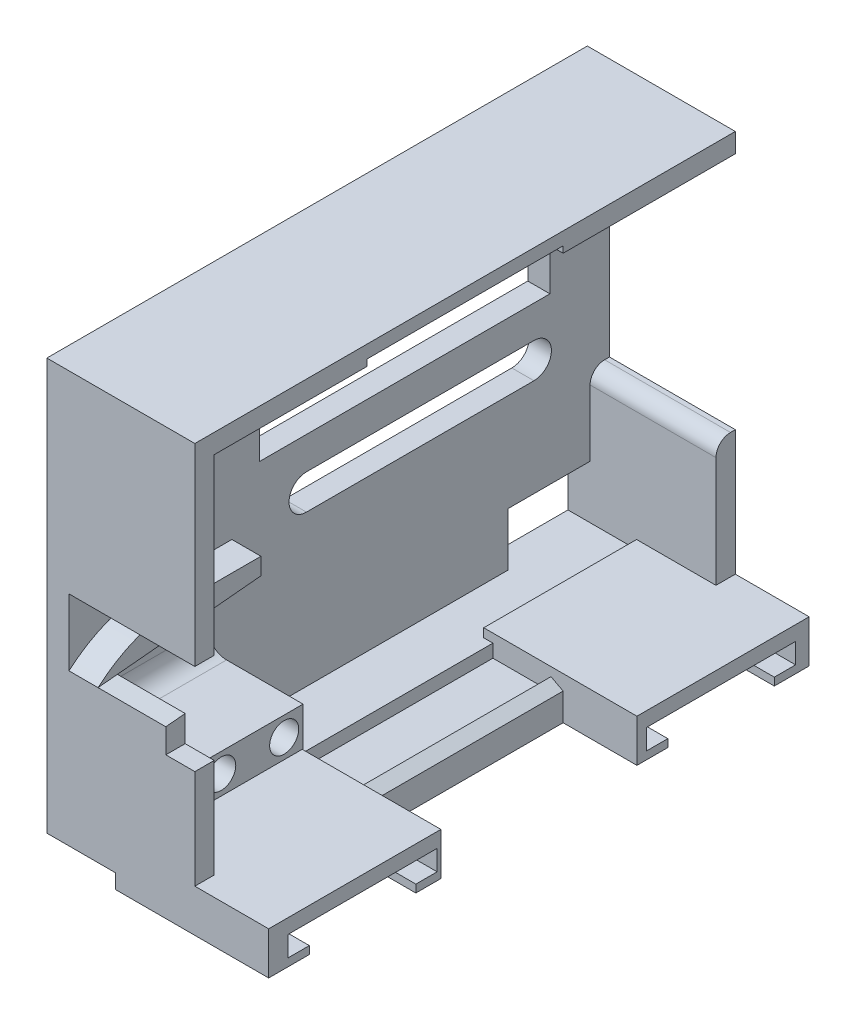
from build123d import *

# Parameters (mm, degrees)
MAIN_EXTRUDE_DEPTH            = 2.2875
WALLS_START                   = 2.2875
WALLS_DEPTH                   = 13
CORNER_SUPPORT_DEPTH          = 2
SKETCH2_R                     = 0.95
SKETCH2_W                     = 2.4
SKETCH2_H                     = 4
SKETCH2_W_2                   = 1
SWITCH_SPACER_DEPTH           = 9.9
ARM_SUPPORT_EXTRUDE_DEPTH     = 3
ARM_SUPPORT_CURVE_DEPTH       = 40.380356778
FILLET4_R                     = 2
FILLET3_R                     = 2
SKETCH2_5_R                   = 0.95
SWITCH_MOUNT_HOLES_DEPTH      = 40.380356889
SWITCH_MOUNT_HOLES_DEPTH_BACK = 40.380356889
SKETCH35_R                    = 1.5
SWITCH_MOUNT_EXIT_HOLES_DEPTH = 3
SKETCH4_W                     = 8.5
SKETCH4_H                     = 5.5
WIRE_HOLE_DEPTH               = 40.380356889
SKETCH25_W                    = 6
SKETCH25_H                    = 1.35
FEMALE_SNAP_DEPTH             = 10.125
SKETCH5_W                     = 30
SKETCH5_H                     = 12.75
SERVO_HOLE_DEPTH              = 40.380356889
SKETCH30_W                    = 15.7875
SKETCH30_H                    = 0.9
SKETCH30_W_2                  = 17.7875
SKETCH30_H_2                  = 1.5
MAGNET_EXTRUDE_1_DEPTH        = 7.625
MAGNET_EXTRUDE_1_DEPTH_BACK   = 8.2
SKETCH30_5_W                  = 20.25
SKETCH30_5_H                  = 1.5
MAGNET_EXTRUDE_2_DEPTH        = 8.2
SKETCH29_R                    = 7.7
MAGNET_HOLE_DEPTH             = 2.1
SKETCH31_R                    = 5.5
MAGNET_THRU_HOLE_DEPTH        = 58.632218961
SKETCH39_W                    = 3.175
SKETCH39_H                    = 12.55
CUT_EXTRUDE1_DEPTH            = 45.416158798
CUT_EXTRUDE2_DEPTH            = 42.895144408
BOSS_EXTRUDE2_DEPTH           = 10


with BuildPart() as part:
    # Sketch1 → Main Extrude (new body)
    with BuildSketch(Plane(origin=(0, 0, 0), x_dir=(0, 0, -1), z_dir=(1, 0, 0))):
        Polygon((-30.5, -9.35), (-27.325, -9.35), (-27.325, -21.25), (28.5, -21.25), (28.5, 21.25), (-27.325, 21.25), (-27.325, 3.2), (-30.5, 3.2), align=None)
        with BuildLine():
            Line((20.7, -3.65), (-2.8, -3.65))
            ThreePointArc((-2.8, -3.65), (-4.6, -1.85), (-2.8, -0.05))
            Line((-2.8, -0.05), (20.7, -0.05))
            ThreePointArc((20.7, -0.05), (22.5, -1.85), (20.7, -3.65))
        make_face(mode=Mode.SUBTRACT)
    extrude(amount=MAIN_EXTRUDE_DEPTH)

    # Sketch1_3 → Walls (add)
    with BuildSketch(Plane(origin=(0, 0, 0), x_dir=(0, 0, -1), z_dir=(1, 0, 0)).offset(WALLS_START)):
        Polygon((-25.325, 19.25), (28.5, 19.25), (28.5, 21.25), (-27.325, 21.25), (-27.325, 3.2), (-30.5, 3.2), (-30.5, 1.3), (-25.325, 1.3), align=None)
        with BuildLine():
            Line((28.5, -5.425), (28, -5.425))
            ThreePointArc((28, -5.425), (26.939339828, -5.864339828), (26.5, -6.925))
            Line((26.5, -6.925), (26.5, -19.25))
            Line((26.5, -19.25), (-25.325, -19.25))
            Line((-25.325, -19.25), (-25.325, -8.1))
            Line((-25.325, -8.1), (-28.5, -8.1))
            Line((-28.5, -8.1), (-28.5, -4.45))
            Line((-28.5, -4.45), (-30.5, -4.45))
            Line((-30.5, -4.45), (-30.5, -9.35))
            Line((-30.5, -9.35), (-27.325, -9.35))
            Line((-27.325, -9.35), (-27.325, -21.25))
            Line((-27.325, -21.25), (28.5, -21.25))
            Line((28.5, -21.25), (28.5, -5.425))
        make_face()
    extrude(amount=WALLS_DEPTH)

    # Sketch22 → Corner Support (add)
    with BuildSketch(Plane(origin=(0, 0, -28.5), x_dir=(-1, 0, 0), z_dir=(0, 0, -1))):
        Polygon((-4.2875, 19.25), (-2.2875, 18.25), (-2.2875, 19.25), align=None)
    extrude(amount=-CORNER_SUPPORT_DEPTH)

    # Sketch2 → Switch Spacer (add)
    with BuildSketch(Plane(origin=(2.2875, 0, 0), x_dir=(0, 0, -1), z_dir=(1, 0, 0))):
        Polygon((-14.05, -10.75), (-17.05, -10.75), (-17.05, -14.75), (-14.05, -14.75), (-14.05, -12.75), align=None)
        with Locations((-15, -12.75)):
            Circle(SKETCH2_R, mode=Mode.SUBTRACT)
        with Locations((-15, -12.75)):
            Circle(SKETCH2_R)
        Polygon((-19.45, -10.75), (-22.45, -10.75), (-22.45, -12.75), (-22.45, -14.75), (-19.45, -14.75), align=None)
        with BuildLine():
            ThreePointArc((-20.55, -12.75), (-21.5, -13.7), (-22.45, -12.75))
            ThreePointArc((-22.45, -12.75), (-21.5, -11.8), (-20.55, -12.75))
        make_face(mode=Mode.SUBTRACT)
        with Locations((-21.5, -12.75)):
            Circle(SKETCH2_R)
        Polygon((-22.45, -12.75), (-22.45, -10.75), (-25.325, -10.75), (-25.325, -14.75), (-22.45, -14.75), align=None)
        with Locations((-18.25, -12.75)):
            Rectangle(SKETCH2_W, SKETCH2_H)
        with Locations((-13.55, -12.75)):
            Rectangle(SKETCH2_W_2, SKETCH2_H)
    extrude(amount=SWITCH_SPACER_DEPTH)

    # Sketch3 → Arm Support Extrude (add)
    with BuildSketch(Plane(origin=(2.2875, 0, 0), x_dir=(0, 0, -1), z_dir=(1, 0, 0))):
        with BuildLine():
            Line((-18.5, -2.25), (-10.5, -2.25))
            Line((-10.5, -2.25), (-10.5, -4))
            Line((-10.5, -4), (-28.5, -5.7))
            Line((-28.5, -5.7), (-30.5, -5.7))
            ThreePointArc((-30.5, -5.7), (-24.743046131, -3.129622151), (-18.5, -2.25))
        make_face()
    extrude(amount=ARM_SUPPORT_EXTRUDE_DEPTH)

    # Sketch7 → Arm Support Curve (cut, through all)
    with BuildSketch(Plane(origin=(2.2875, 0, 0), x_dir=(0, 0, -1), z_dir=(1, 0, 0))):
        with BuildLine():
            Line((-28.5, -4.583410824), (-28.5, -4.45))
            Line((-28.5, -4.45), (-30.5, -4.45))
            Line((-30.5, -4.45), (-30.5, -5.7))
            ThreePointArc((-30.5, -5.7), (-29.627655409, -5.180138898), (-28.73283292, -4.7))
            ThreePointArc((-28.73283292, -4.7), (-28.616584416, -4.641369997), (-28.5, -4.583410824))
        make_face()
    extrude(amount=ARM_SUPPORT_CURVE_DEPTH, mode=Mode.SUBTRACT)

    # Fillet4
    fillet4_edges = [part.edges().sort_by_distance(p)[0] for p in [
        (2.2875, -2.2, 30.5),
    ]]
    fillet(fillet4_edges, radius=FILLET4_R)

    # Fillet3
    fillet3_edges = [part.edges().sort_by_distance(p)[0] for p in [
        (2.2875, -14.75, 19.1875),
        (2.2875, -10.75, 19.1875),
    ]]
    fillet(fillet3_edges, radius=FILLET3_R)

    # Sketch2_5 → Switch Mount Holes (cut, two sides)
    with BuildSketch(Plane(origin=(2.2875, 0, 0), x_dir=(0, 0, -1), z_dir=(1, 0, 0))) as switch_mount_holes_sk:
        with Locations((-21.5, -12.75)):
            Circle(SKETCH2_5_R)
        with Locations((-15, -12.75)):
            Circle(SKETCH2_5_R)
    extrude(amount=SWITCH_MOUNT_HOLES_DEPTH, mode=Mode.SUBTRACT)
    extrude(switch_mount_holes_sk.sketch, amount=-SWITCH_MOUNT_HOLES_DEPTH_BACK, mode=Mode.SUBTRACT)

    # Sketch35 → Switch Mount Exit Holes (cut)
    with BuildSketch(Plane(origin=(12.1875, 0, 0), x_dir=(0, 0, -1), z_dir=(1, 0, 0))):
        with Locations((-21.5, -12.75)):
            Circle(SKETCH35_R)
        with Locations((-15, -12.75)):
            Circle(SKETCH35_R)
    extrude(amount=-SWITCH_MOUNT_EXIT_HOLES_DEPTH, mode=Mode.SUBTRACT)

    # Sketch4 → Wire Hole (cut, through all)
    with BuildSketch(Plane(origin=(2.2875, 0, 0), x_dir=(0, 0, -1), z_dir=(1, 0, 0))):
        with Locations((22.25, -16.5)):
            Rectangle(SKETCH4_W, SKETCH4_H)
    extrude(amount=-WIRE_HOLE_DEPTH, mode=Mode.SUBTRACT)

    # Sketch25 → Female Snap (cut, symmetric)
    with BuildSketch(Plane(origin=(0, 0, -0.5875), x_dir=(-1, 0, 0), z_dir=(0, 0, -1))):
        with Locations((-11.0375, -19.925)):
            Rectangle(SKETCH25_W, SKETCH25_H)
        Polygon((-15.2875, -19.25), (-15.2875, -19.91463679), (-14.0375, -19.25), align=None)
        with Locations((-11.0375, 19.925)):
            Rectangle(SKETCH25_W, SKETCH25_H)
        Polygon((-15.2875, 19.91463679), (-15.2875, 19.25), (-14.0375, 19.25), align=None)
    extrude(amount=FEMALE_SNAP_DEPTH, both=True, mode=Mode.SUBTRACT)

    # Sketch5 → Servo Hole (cut, through all)
    with BuildSketch(Plane(origin=(2.2875, 0, 0), x_dir=(0, 0, -1), z_dir=(1, 0, 0))):
        with Locations((7.35, 9.675)):
            Rectangle(SKETCH5_W, SKETCH5_H)
        with BuildLine():
            Line((-8.75, 10.675), (-8.75, 8.675))
            ThreePointArc((-8.75, 8.675), (-10.3, 7.125), (-11.85, 8.675))
            Line((-11.85, 8.675), (-11.85, 10.675))
            ThreePointArc((-11.85, 10.675), (-10.3, 12.225), (-8.75, 10.675))
        make_face()
        with BuildLine():
            Line((26.55, 10.675), (26.55, 8.675))
            ThreePointArc((26.55, 8.675), (25, 7.125), (23.45, 8.675))
            Line((23.45, 8.675), (23.45, 10.675))
            ThreePointArc((23.45, 10.675), (25, 12.225), (26.55, 10.675))
        make_face()
    extrude(amount=-SERVO_HOLE_DEPTH, mode=Mode.SUBTRACT)

    # Sketch30 → Magnet Extrude 1 (add, two sides)
    with BuildSketch(Plane(origin=(15.2875, 0, 0), x_dir=(0, 0, -1), z_dir=(1, 0, 0))) as magnet_extrude_1_sk:
        Polygon((-27.325, -18.35), (-27.325, -21.25), (-9.5375, -21.25), (-9.5375, -19.91463679), (-9.5375, -19.25), (-25.325, -19.25), (-25.325, -18.35), align=None)
        with Locations((-17.43125, -18.8)):
            Rectangle(SKETCH30_W, SKETCH30_H)
        with Locations((19.60625, -22)):
            Rectangle(SKETCH30_W_2, SKETCH30_H_2)
        Polygon((10.7125, -19.91463679), (10.7125, -21.25), (28.5, -21.25), (28.5, -18.35), (26.5, -18.35), (26.5, -19.25), (10.7125, -19.25), align=None)
        with Locations((-18.43125, -22)):
            Rectangle(SKETCH30_W_2, SKETCH30_H_2)
        with Locations((18.60625, -18.8)):
            Rectangle(SKETCH30_W, SKETCH30_H)
    extrude(amount=MAGNET_EXTRUDE_1_DEPTH)
    extrude(magnet_extrude_1_sk.sketch, amount=-MAGNET_EXTRUDE_1_DEPTH_BACK)

    # Sketch30_5 → Magnet Extrude 2 (add)
    with BuildSketch(Plane(origin=(15.2875, 0, 0), x_dir=(0, 0, -1), z_dir=(1, 0, 0))):
        with Locations((0.5875, -22)):
            Rectangle(SKETCH30_5_W, SKETCH30_5_H)
    extrude(amount=-MAGNET_EXTRUDE_2_DEPTH)

    # Sketch29 → Magnet Hole (cut)
    with BuildSketch(Plane(origin=(0, -21.95, 0), x_dir=(1, 0, 0), z_dir=(0, 1, 0))):
        with Locations((15.2875, -17.625)):
            Circle(SKETCH29_R)
        with BuildLine():
            ThreePointArc((22.9125, -18.697089082), (20.338980677, -23.436414885), (15.2875, -25.325))
            Line((15.2875, -25.325), (22.9125, -25.325))
            Line((22.9125, -25.325), (22.9125, -18.697089082))
        make_face()
        with BuildLine():
            Line((22.9125, -9.925), (15.2875, -9.925))
            ThreePointArc((15.2875, -9.925), (20.338980677, -11.813585115), (22.9125, -16.552910918))
            Line((22.9125, -16.552910918), (22.9125, -9.925))
        make_face()
        with Locations((15.2875, 19.4)):
            Circle(SKETCH29_R)
        with BuildLine():
            ThreePointArc((22.9125, 18.327910918), (20.338980677, 13.588585115), (15.2875, 11.7))
            Line((15.2875, 11.7), (22.9125, 11.7))
            Line((22.9125, 11.7), (22.9125, 18.327910918))
        make_face()
        with BuildLine():
            Line((22.9125, 27.1), (15.2875, 27.1))
            ThreePointArc((15.2875, 27.1), (20.338980677, 25.211414885), (22.9125, 20.472089082))
            Line((22.9125, 20.472089082), (22.9125, 27.1))
        make_face()
        with BuildLine():
            ThreePointArc((22.9875, -17.625), (22.968727116, -17.087645368), (22.9125, -16.552910918))
            Line((22.9125, -16.552910918), (22.9125, -18.697089082))
            ThreePointArc((22.9125, -18.697089082), (22.968727116, -18.162354632), (22.9875, -17.625))
        make_face()
        with BuildLine():
            Line((22.9125, 20.472089082), (22.9125, 18.327910918))
            ThreePointArc((22.9125, 18.327910918), (22.968727116, 18.862645368), (22.9875, 19.4))
            ThreePointArc((22.9875, 19.4), (22.968727116, 19.937354632), (22.9125, 20.472089082))
        make_face()
    extrude(amount=MAGNET_HOLE_DEPTH, mode=Mode.SUBTRACT)

    # Sketch31 → Magnet Thru Hole (cut, through all)
    with BuildSketch(Plane.XZ.offset(21.95)):
        with Locations((15.2875, 17.625)):
            Circle(SKETCH31_R)
        with BuildLine():
            Line((22.9125, 23.125), (15.2875, 23.125))
            ThreePointArc((15.2875, 23.125), (19.176587297, 21.514087297), (20.7875, 17.625))
            ThreePointArc((20.7875, 17.625), (19.176587297, 13.735912703), (15.2875, 12.125))
            Line((15.2875, 12.125), (22.9125, 12.125))
            Line((22.9125, 12.125), (22.9125, 23.125))
        make_face()
        with Locations((15.2875, -19.4)):
            Circle(SKETCH31_R)
        with BuildLine():
            Line((22.9125, -13.9), (15.2875, -13.9))
            ThreePointArc((15.2875, -13.9), (19.176587297, -15.510912703), (20.7875, -19.4))
            ThreePointArc((20.7875, -19.4), (19.176587297, -23.289087297), (15.2875, -24.9))
            Line((15.2875, -24.9), (22.9125, -24.9))
            Line((22.9125, -24.9), (22.9125, -13.9))
        make_face()
    extrude(amount=MAGNET_THRU_HOLE_DEPTH, mode=Mode.SUBTRACT)

    # Sketch39 → Cut-Extrude1 (cut, through all)
    with BuildSketch(Plane.ZY):
        with Locations((28.9125, -3.075)):
            Rectangle(SKETCH39_W, SKETCH39_H)
    extrude(amount=-CUT_EXTRUDE1_DEPTH, mode=Mode.SUBTRACT)

    # Sketch40 → Cut-Extrude2 (cut, through all)
    with BuildSketch(Plane(origin=(2.2875, 0, 0), x_dir=(0, 0, -1), z_dir=(1, 0, 0))):
        with BuildLine():
            Line((-27.325, -5.589027778), (-27.325, -4.044715402))
            ThreePointArc((-27.325, -4.044715402), (-23.002822125, -2.703224466), (-18.5, -2.25))
            ThreePointArc((-18.5, -2.25), (-23.217778383, -3.112667731), (-27.325, -5.589027778))
        make_face()
    extrude(amount=CUT_EXTRUDE2_DEPTH, mode=Mode.SUBTRACT)

    # Sketch41 → Boss-Extrude2 (add)
    with BuildSketch(Plane(origin=(2.2875, 0, 0), x_dir=(0, 0, -1), z_dir=(1, 0, 0))):
        Polygon((-25.325, -8.1), (-27.325, -8.1), (-27.325, -5.589027778), (-25.325, -5.400138889), align=None)
    extrude(amount=BOSS_EXTRUDE2_DEPTH)


solid = part.part
